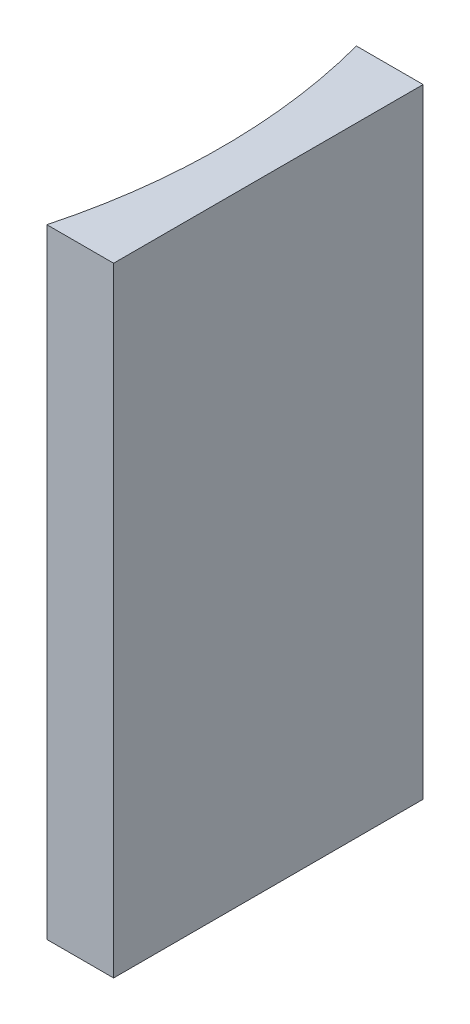
from build123d import *

# Parameters (mm, degrees)
EXTRUDE_1_DEPTH = 40


with BuildPart() as part:
    # 草图1 → 凸台-拉伸1 (new body)
    with BuildSketch(Plane(origin=(0, 0, 0), x_dir=(1, 0, 0), z_dir=(0, 1, 0))):
        with BuildLine():
            Line((0, 0), (0, -20))
            Line((0, -20), (-4.311501231, -20))
            ThreePointArc((-4.311501231, -20), (-3, -10), (-4.311501231, 0))
            Line((-4.311501231, 0), (0, 0))
        make_face()
    extrude(amount=EXTRUDE_1_DEPTH)


solid = part.part
